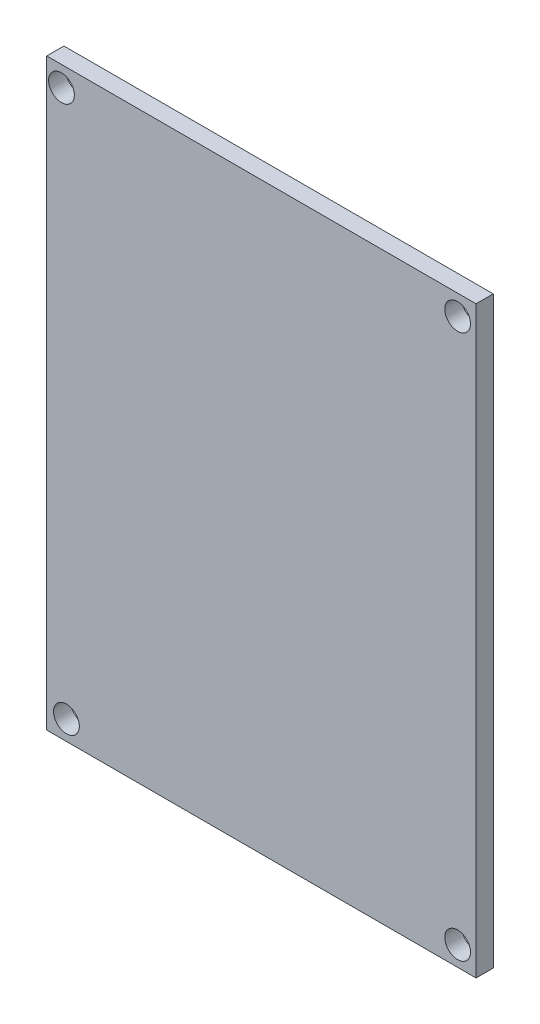
from build123d import *

# Parameters (mm, degrees)
SKETCH1_W           = 50
SKETCH1_H           = 68
BOSS_EXTRUDE1_DEPTH = 2
SKETCH2_R           = 1.5
CUT_EXTRUDE1_DEPTH  = 2


with BuildPart() as part:
    # Sketch1 → Boss-Extrude1 (new body)
    with BuildSketch(Plane.XY):
        Rectangle(SKETCH1_W, SKETCH1_H)
    extrude(amount=BOSS_EXTRUDE1_DEPTH)

    # Sketch2 → Cut-Extrude1 (cut)
    with BuildSketch(Plane(origin=(0, 0, 0), x_dir=(-1, 0, 0), z_dir=(0, 0, -1))):
        with Locations((23.28579951, 31.651304466)):
            Circle(SKETCH2_R)
        with Locations((-22.851227824, 31.651304466)):
            Circle(SKETCH2_R)
        with Locations((-22.851227824, -31.72373308)):
            Circle(SKETCH2_R)
        with Locations((22.706370595, -31.72373308)):
            Circle(SKETCH2_R)
    extrude(amount=-CUT_EXTRUDE1_DEPTH, mode=Mode.SUBTRACT)


solid = part.part
